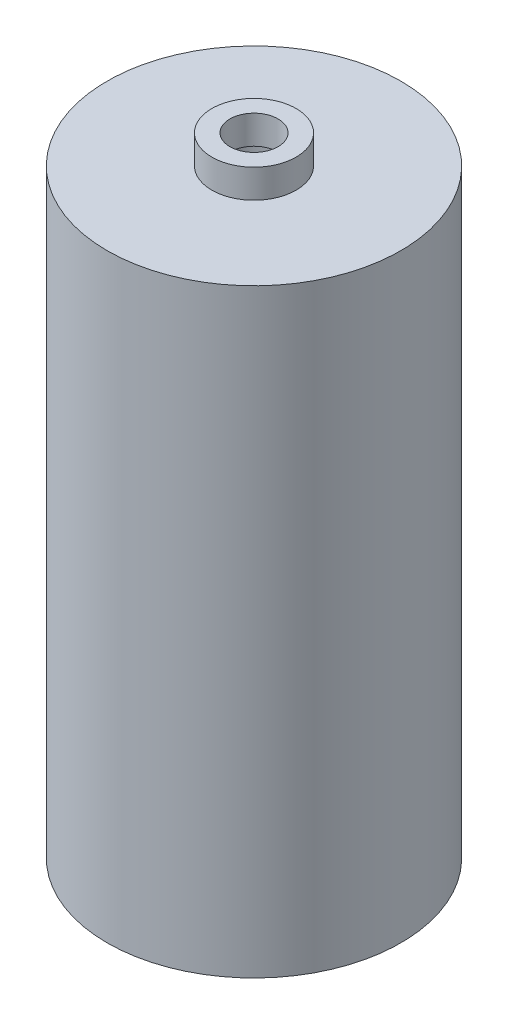
from build123d import *

# Parameters (mm, degrees)
SKETCH3_R           = 12.2
SKETCH3_R_2         = 3.2
BOSS_EXTRUDE1_DEPTH = 49.8
SKETCH4_R           = 3.5
SKETCH4_R_2         = 2
BOSS_EXTRUDE2_DEPTH = 2.38


with BuildPart() as part:
    # Sketch3 → Boss-Extrude1 (new body)
    with BuildSketch(Plane(origin=(0, 0, 0), x_dir=(1, 0, 0), z_dir=(0, 1, 0))):
        Circle(SKETCH3_R)
        Circle(SKETCH3_R_2, mode=Mode.SUBTRACT)
    extrude(amount=BOSS_EXTRUDE1_DEPTH)

    # Sketch4 → Boss-Extrude2 (add)
    with BuildSketch(Plane(origin=(0, 49.8, 0), x_dir=(1, 0, 0), z_dir=(0, 1, 0))):
        Circle(SKETCH4_R)
        Circle(SKETCH4_R_2, mode=Mode.SUBTRACT)
    extrude(amount=BOSS_EXTRUDE2_DEPTH)


solid = part.part
